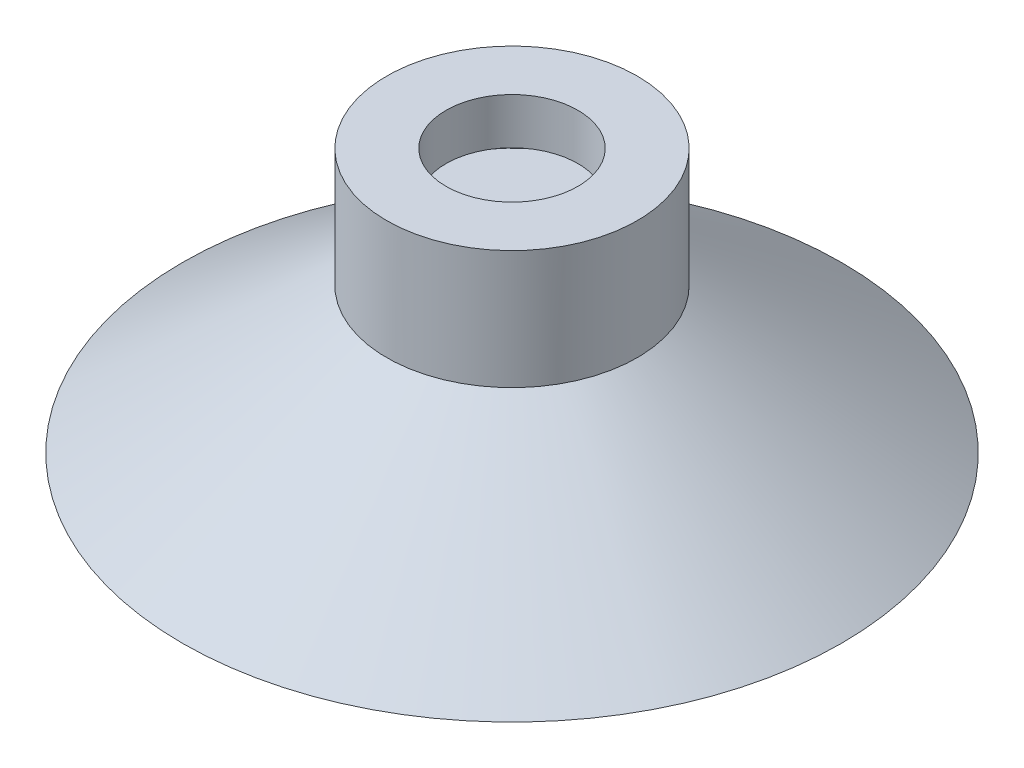
from build123d import *

# Parameters (mm, degrees)
SKETCH_4_R          = 9.5
EXTRUDE_1_DEPTH     = 9
SKETCH_5_R          = 5
CUT_EXTRUDE_1_DEPTH = 3.5
SKETCH_6_R          = 8.5
CUT_EXTRUDE_2_DEPTH = 2.5


with BuildPart() as part:
    # 草图4 → 凸台-拉伸1 (new body)
    with BuildSketch(Plane(origin=(0, 0, 0), x_dir=(1, 0, 0), z_dir=(0, 1, 0))):
        Circle(SKETCH_4_R)
    extrude(amount=EXTRUDE_1_DEPTH)

    # 草图5 → 切除-拉伸1 (cut)
    with BuildSketch(Plane(origin=(0, 9, 0), x_dir=(1, 0, 0), z_dir=(0, 1, 0))):
        Circle(SKETCH_5_R)
    extrude(amount=-CUT_EXTRUDE_1_DEPTH, mode=Mode.SUBTRACT)

    # 草图6 → 切除-拉伸2 (cut)
    with BuildSketch(Plane(origin=(0, 5.5, 0), x_dir=(1, 0, 0), z_dir=(0, 1, 0))):
        Circle(SKETCH_6_R)
    extrude(amount=-CUT_EXTRUDE_2_DEPTH, mode=Mode.SUBTRACT)

    # 草图8 → 旋转3 (revolve)
    with BuildSketch(Plane.XY):
        Polygon((9.5, 0), (25, -11), (21.54425858, -11), (6.04425858, 0), align=None)
    revolve(axis=Axis((0, 0, 0), (0, 1, 0)))


solid = part.part
